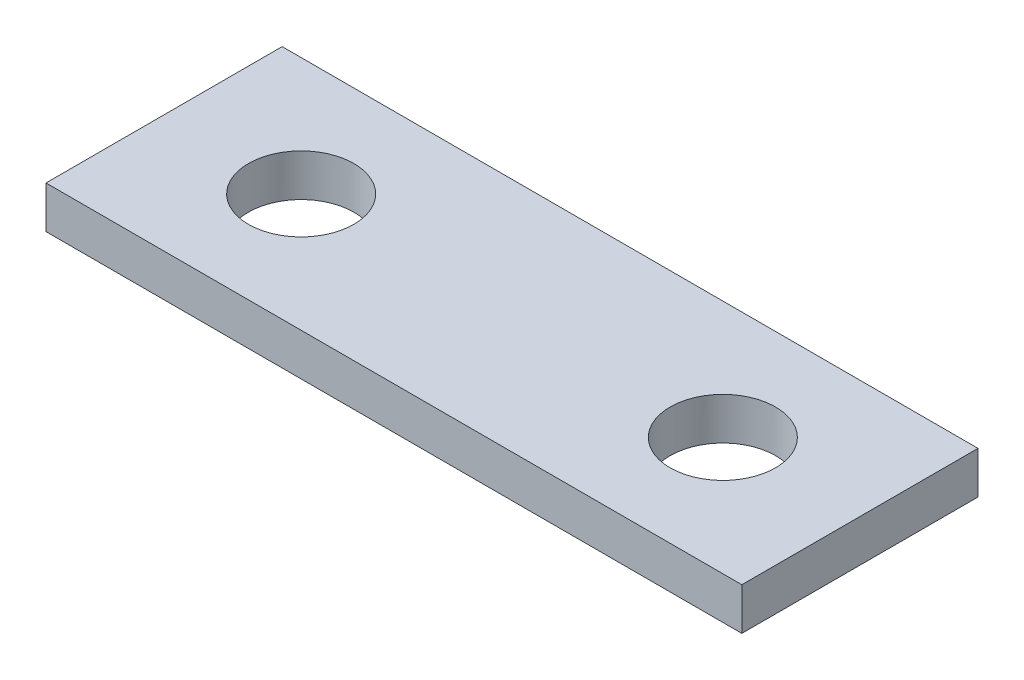
from build123d import *

# Parameters (mm, degrees)
SKETCH1_W                 = 16.5
SKETCH1_H                 = 5.6
BOSS_EXTRUDE1_DEPTH       = 1
M3X0_5_TAPPED_HOLE3_D     = 2.5
M3X0_5_TAPPED_HOLE3_DEPTH = 1


with BuildPart() as part:
    # Sketch1 → Boss-Extrude1 (new body)
    with BuildSketch(Plane(origin=(0, 0, 0), x_dir=(1, 0, 0), z_dir=(0, 1, 0))):
        with Locations((8.25, 2.8)):
            Rectangle(SKETCH1_W, SKETCH1_H)
    extrude(amount=BOSS_EXTRUDE1_DEPTH)

    # M3x0.5 Tapped Hole3
    with Locations(Plane(origin=(0, 1, 0), x_dir=(-1, 0, 0), z_dir=(0, 1, 0))):
        with Locations((-3.25, -2.8), (-13.25, -2.8)):
            Hole(M3X0_5_TAPPED_HOLE3_D / 2, depth=M3X0_5_TAPPED_HOLE3_DEPTH)


solid = part.part
